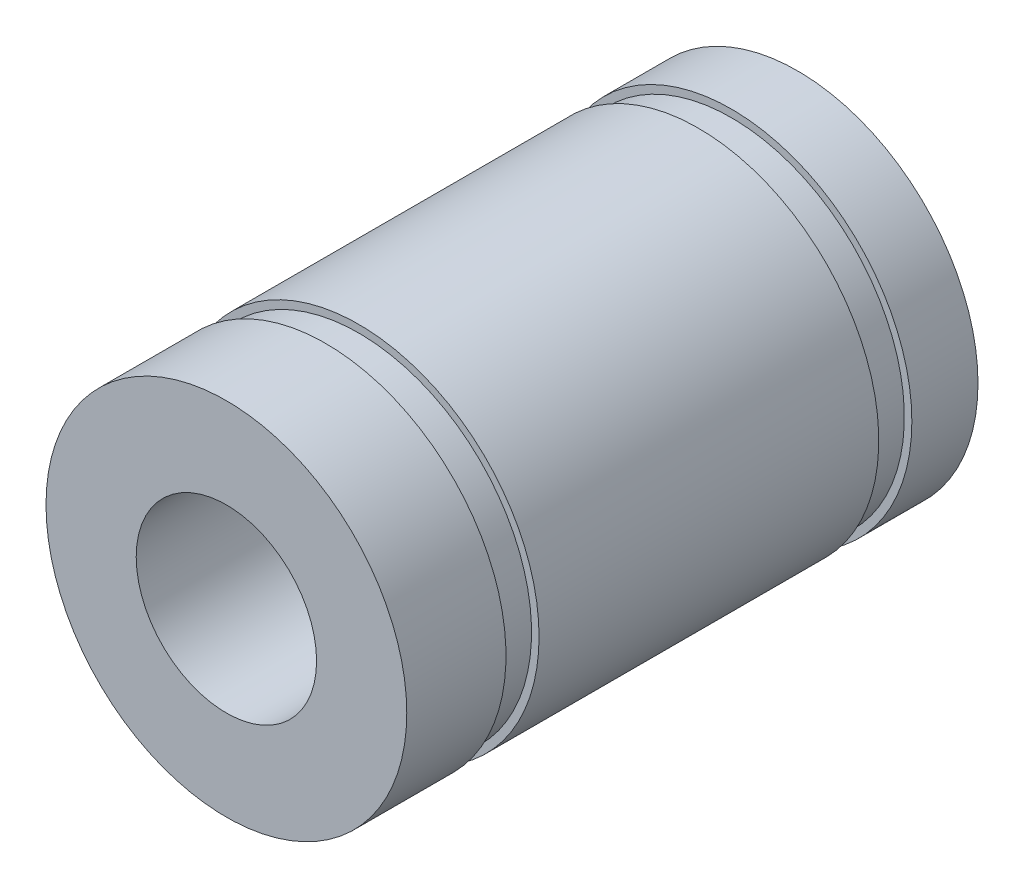
from build123d import *

# Parameters (mm, degrees)
SKETCH1_R           = 6
SKETCH1_R_2         = 3
BOSS_EXTRUDE1_DEPTH = 19
SKETCH2_W           = 1.849781756
SKETCH2_H           = 1.1


with BuildPart() as part:
    # Sketch1 → Boss-Extrude1 (new body)
    with BuildSketch(Plane.XY):
        Circle(SKETCH1_R)
        Circle(SKETCH1_R_2, mode=Mode.SUBTRACT)
    extrude(amount=BOSS_EXTRUDE1_DEPTH)

    # Sketch2 → Cut-Revolve1 (revolve, cut)
    with BuildSketch(Plane(origin=(0, 0, 0), x_dir=(1, 0, 0), z_dir=(0, 1, 0))):
        with Locations((6.674890878, -2.75)):
            Rectangle(SKETCH2_W, SKETCH2_H)
        with Locations((6.674890878, -15.15)):
            Rectangle(SKETCH2_W, SKETCH2_H)
    revolve(axis=Axis((0, 0, 0), (0, 0, 1)), mode=Mode.SUBTRACT)


solid = part.part
